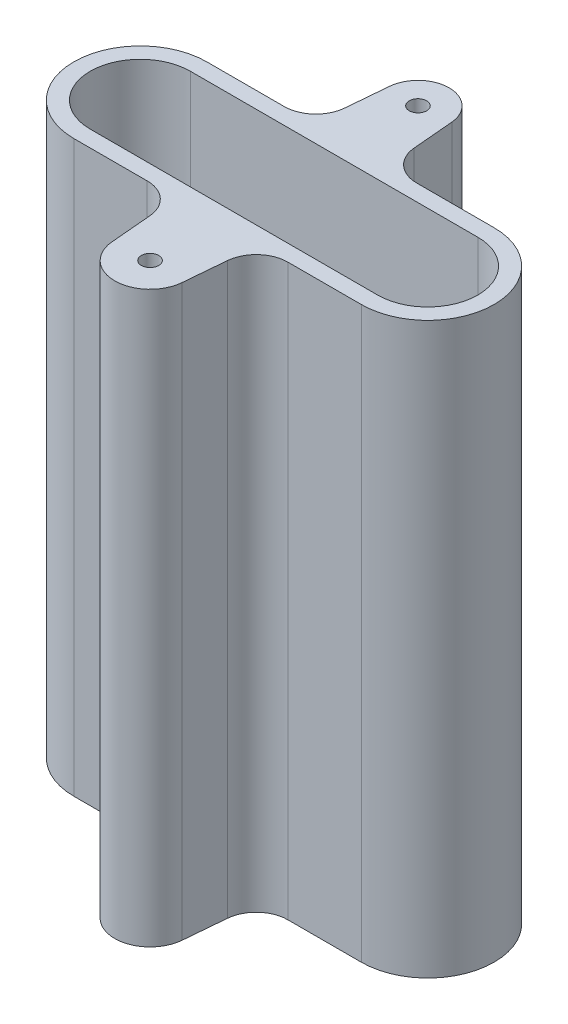
from build123d import *

# Parameters (mm, degrees)
SKETCH1_R      = 0.825
EXTRUDE1_DEPTH = 54


with BuildPart() as part:
    # Sketch1 → Extrude1 (new body)
    with BuildSketch(Plane(origin=(0, 0, 0), x_dir=(1, 0, 0), z_dir=(0, 1, 0))):
        with BuildLine():
            Line((-2.945413127, 12.957690258), (-3.288294978, 9.038532772))
            ThreePointArc((-3.288294978, 9.038532772), (-4.250108449, 7.08816799), (-6.276879072, 6.3))
            Line((-6.276879072, 6.3), (-13.625, 6.3))
            ThreePointArc((-13.625, 6.3), (-19.925, 0), (-13.625, -6.3))
            Line((-13.625, -6.3), (-6.666750968, -6.3))
            ThreePointArc((-6.666750968, -6.3), (-4.639980345, -7.08816799), (-3.678166874, -9.038532772))
            Line((-3.678166874, -9.038532772), (-3.332323508, -12.99154053))
            ThreePointArc((-3.332323508, -12.99154053), (0, -16.045052443), (3.332323508, -12.99154053))
            Line((3.332323508, -12.99154053), (3.678166874, -9.038532772))
            ThreePointArc((3.678166874, -9.038532772), (4.639980345, -7.08816799), (6.666750968, -6.3))
            Line((6.666750968, -6.3), (13.625, -6.3))
            ThreePointArc((13.625, -6.3), (19.925, 0), (13.625, 6.3))
            Line((13.625, 6.3), (6.276879072, 6.3))
            ThreePointArc((6.276879072, 6.3), (4.250108449, 7.08816799), (3.288294978, 9.038532772))
            Line((3.288294978, 9.038532772), (2.945413127, 12.957690258))
            ThreePointArc((2.945413127, 12.957690258), (0, 15.656664127), (-2.945413127, 12.957690258))
        make_face()
        with Locations((0, 12.7)):
            Circle(SKETCH1_R, mode=Mode.SUBTRACT)
        with Locations((0, -12.7)):
            Circle(SKETCH1_R, mode=Mode.SUBTRACT)
        with BuildLine():
            Line((-13.625, 4.75), (13.625, 4.75))
            ThreePointArc((13.625, 4.75), (18.375, 0), (13.625, -4.75))
            Line((13.625, -4.75), (-13.625, -4.75))
            ThreePointArc((-13.625, -4.75), (-18.375, 0), (-13.625, 4.75))
        make_face(mode=Mode.SUBTRACT)
    extrude(amount=EXTRUDE1_DEPTH)


solid = part.part
